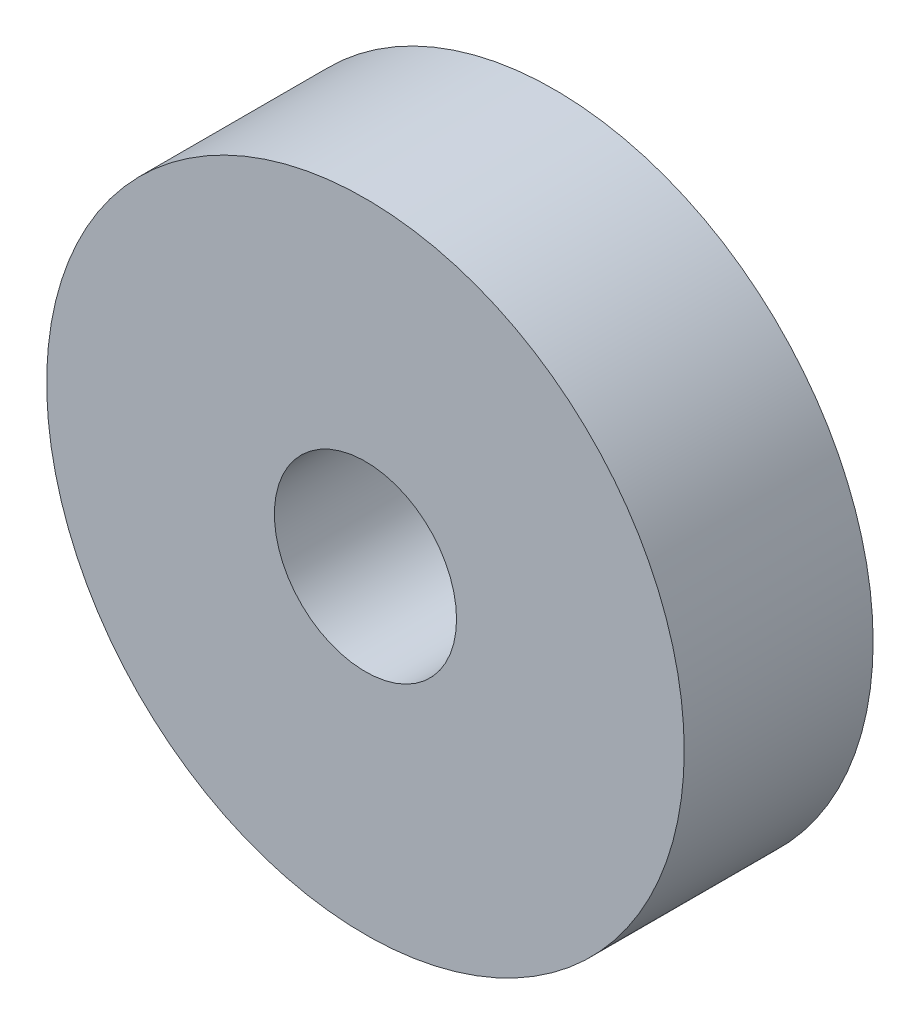
from build123d import *

# Parameters (mm, degrees)
SKICA1_R                = 33.75
SKICA1_R_2              = 9.642857143
P_IDAT_VYSUNUT_M1_DEPTH = 20


with BuildPart() as part:
    # Skica1 → Přidat vysunutím1 (new body)
    with BuildSketch(Plane.XY):
        Circle(SKICA1_R)
        Circle(SKICA1_R_2, mode=Mode.SUBTRACT)
    extrude(amount=P_IDAT_VYSUNUT_M1_DEPTH)


solid = part.part
